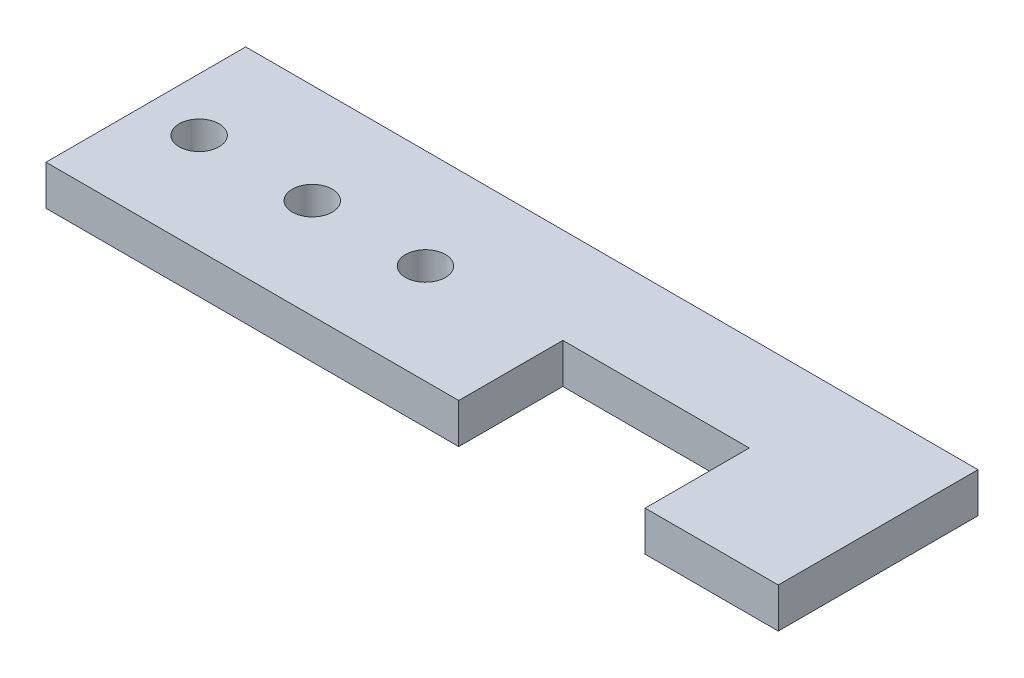
from build123d import *

# Parameters (mm, degrees)
ESQUISSE1_R        = 1.5
BOSS_EXTRU_2_DEPTH = 3


with BuildPart() as part:
    # Esquisse1 → Boss.-Extru.2 (new body)
    with BuildSketch(Plane(origin=(0, 0, 0), x_dir=(1, 0, 0), z_dir=(0, 1, 0))):
        Polygon((0, 0), (31, 0), (31, 7.820303555), (45, 7.820303555), (45, 0), (55, 0), (55, 15), (0, 15), align=None)
        with Locations((4, 7.5)):
            Circle(ESQUISSE1_R, mode=Mode.SUBTRACT)
        with Locations((12.5, 7.5)):
            Circle(ESQUISSE1_R, mode=Mode.SUBTRACT)
        with Locations((21, 7.5)):
            Circle(ESQUISSE1_R, mode=Mode.SUBTRACT)
    extrude(amount=BOSS_EXTRU_2_DEPTH)


solid = part.part
